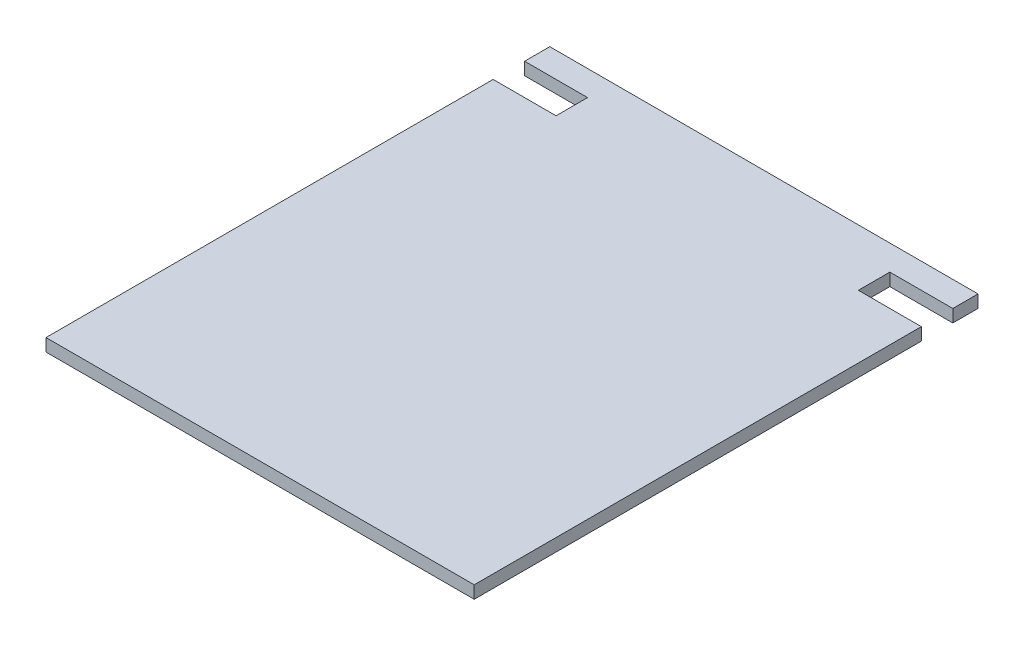
from build123d import *

# Parameters (mm, degrees)
SKETCH2_W           = 340
SKETCH2_H           = 400
BOSS_EXTRUDE1_DEPTH = 10
SKETCH3_W           = 50
SKETCH3_H           = 25
CUT_EXTRUDE1_DEPTH  = 10


with BuildPart() as part:
    # Sketch2 → Boss-Extrude1 (new body)
    with BuildSketch(Plane(origin=(0, 0, 0), x_dir=(1, 0, 0), z_dir=(0, 1, 0))):
        Rectangle(SKETCH2_W, SKETCH2_H)
    extrude(amount=BOSS_EXTRUDE1_DEPTH)

    # Sketch3 → Cut-Extrude1 (cut)
    with BuildSketch(Plane(origin=(0, 10, 0), x_dir=(1, 0, 0), z_dir=(0, 1, 0))):
        with Locations((-145, 167.5)):
            Rectangle(SKETCH3_W, SKETCH3_H)
        with Locations((145, 167.5)):
            Rectangle(SKETCH3_W, SKETCH3_H)
    extrude(amount=-CUT_EXTRUDE1_DEPTH, mode=Mode.SUBTRACT)


solid = part.part
